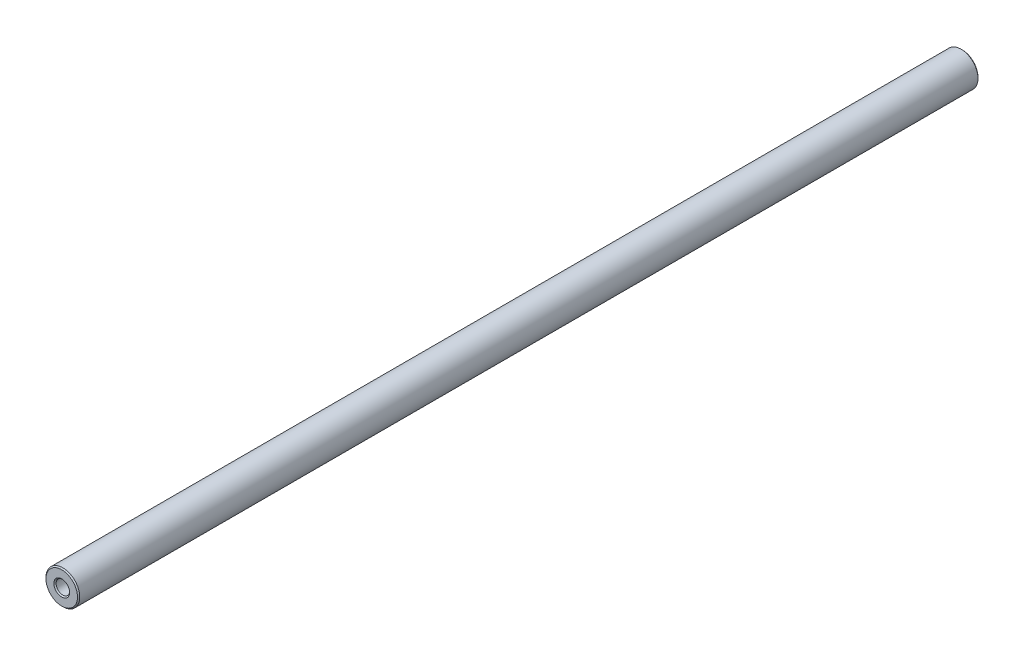
from build123d import *

# Parameters (mm, degrees)
SKETCH1_R           = 3
BOSS_EXTRUDE1_DEPTH = 160
SKETCH2_R           = 1.2
CUT_EXTRUDE1_DEPTH  = 12
SKETCH3_R           = 1.2
CUT_EXTRUDE2_DEPTH  = 12
CHAMFER1_SIZE       = 0.2


with BuildPart() as part:
    # Sketch1 → Boss-Extrude1 (new body)
    with BuildSketch(Plane.XY):
        Circle(SKETCH1_R)
    extrude(amount=BOSS_EXTRUDE1_DEPTH)

    # Sketch2 → Cut-Extrude1 (cut)
    with BuildSketch(Plane.XY.offset(160)):
        Circle(SKETCH2_R)
    extrude(amount=-CUT_EXTRUDE1_DEPTH, mode=Mode.SUBTRACT)

    # Sketch3 → Cut-Extrude2 (cut)
    with BuildSketch(Plane(origin=(0, 0, 0), x_dir=(-1, 0, 0), z_dir=(0, 0, -1))):
        Circle(SKETCH3_R)
    extrude(amount=-CUT_EXTRUDE2_DEPTH, mode=Mode.SUBTRACT)

    # Chamfer1
    chamfer1_edges = [part.edges().sort_by_distance(p)[0] for p in [
        (1.2, 0, 0),
        (-3, 0, 0),
        (-3, 0, 160),
        (-1.2, 0, 160),
    ]]
    chamfer(chamfer1_edges, length=CHAMFER1_SIZE)


solid = part.part
